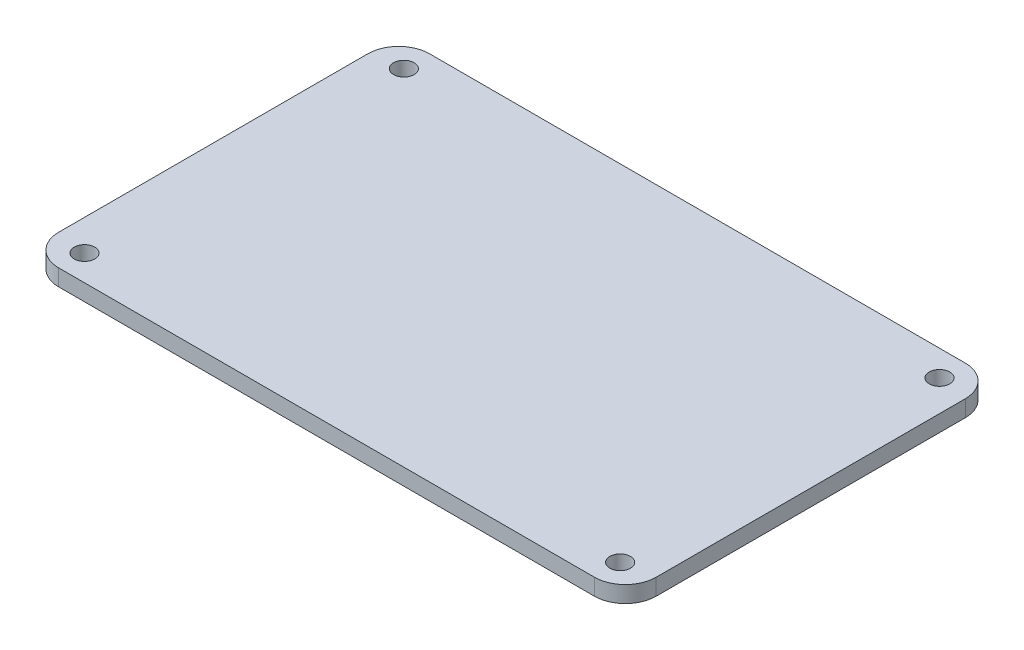
from build123d import *

# Parameters (mm, degrees)
SKETCH1_W           = 58
SKETCH1_H           = 36
SKETCH1_R           = 1
BOSS_EXTRUDE1_DEPTH = 1.6
FILLET1_R           = 3


with BuildPart() as part:
    # Sketch1 → Boss-Extrude1 (new body)
    with BuildSketch(Plane(origin=(0, 0, 0), x_dir=(1, 0, 0), z_dir=(0, 1, 0))):
        with Locations((29, 18)):
            Rectangle(SKETCH1_W, SKETCH1_H)
        with Locations((3.001832039, 2.5)):
            Circle(SKETCH1_R, mode=Mode.SUBTRACT)
        with Locations((54.998167961, 2.5)):
            Circle(SKETCH1_R, mode=Mode.SUBTRACT)
        with Locations((54.998167961, 33.5)):
            Circle(SKETCH1_R, mode=Mode.SUBTRACT)
        with Locations((3.001832039, 33.5)):
            Circle(SKETCH1_R, mode=Mode.SUBTRACT)
    extrude(amount=BOSS_EXTRUDE1_DEPTH)

    # Fillet1
    fillet1_edges = [part.edges().sort_by_distance(p)[0] for p in [
        (0, 0.8, -36),
        (58, 0.8, -36),
        (58, 0.8, 0),
        (0, 0.8, 0),
    ]]
    fillet(fillet1_edges, radius=FILLET1_R)


solid = part.part
